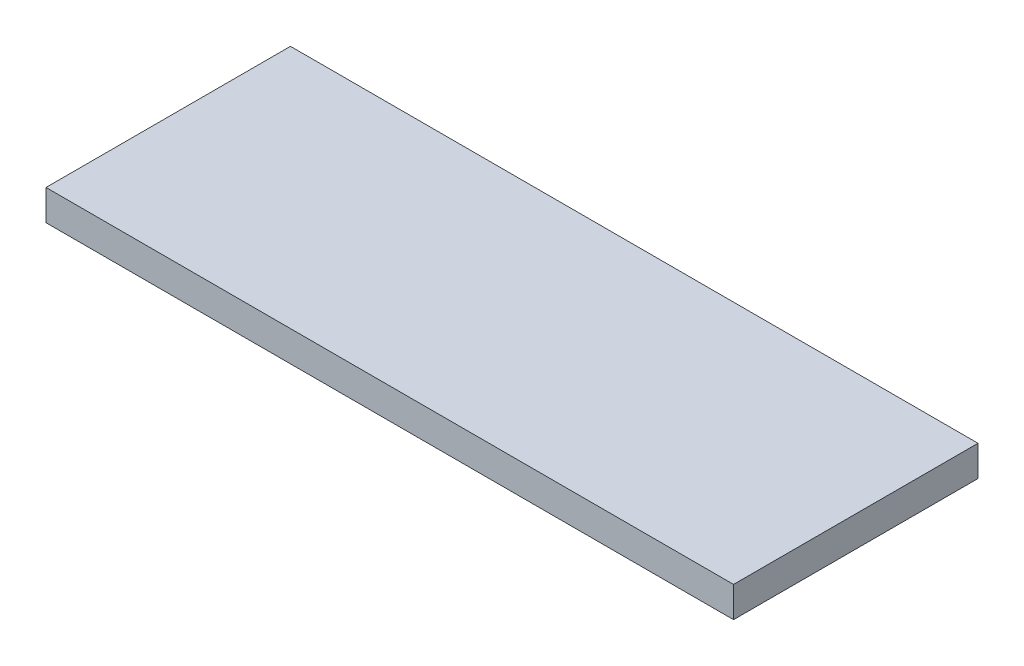
from build123d import *

# Parameters (mm, degrees)
SKETCH1_W           = 450
SKETCH1_H           = 160
BOSS_EXTRUDE1_DEPTH = 20


with BuildPart() as part:
    # Sketch1 → Boss-Extrude1 (new body)
    with BuildSketch(Plane(origin=(0, 0, 0), x_dir=(1, 0, 0), z_dir=(0, 1, 0))):
        Rectangle(SKETCH1_W, SKETCH1_H)
    extrude(amount=BOSS_EXTRUDE1_DEPTH)


solid = part.part
